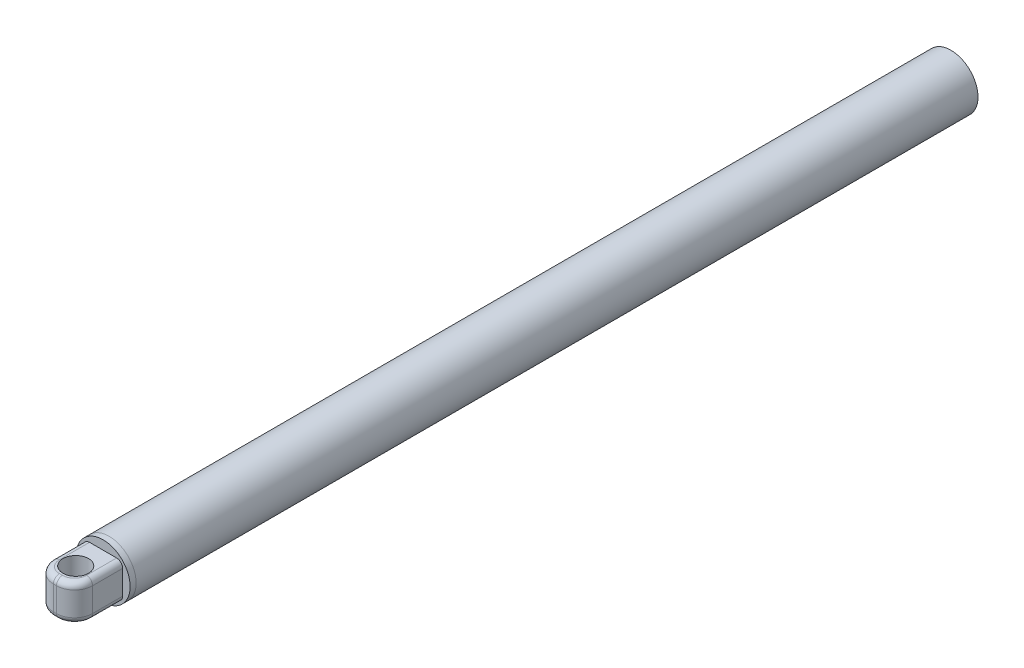
from build123d import *

# Parameters (mm, degrees)
SKETCH1_R                = 4.5
ROD_DEPTH                = 140
SKETCH2_R                = 4.5
BOSS_EXTRUDE2_DEPTH      = 1
BOSS_EXTRUDE4_DEPTH      = 3
BOSS_EXTRUDE4_DEPTH_BACK = 3
SKETCH4_R                = 2.125
FILLET2_R                = 1


with BuildPart() as part:
    # Sketch1 → Rod (new body)
    with BuildSketch(Plane.XY):
        Circle(SKETCH1_R)
    extrude(amount=ROD_DEPTH)


with BuildPart() as body_2:
    # Sketch2 → Boss-Extrude2 (new body)
    with BuildSketch(Plane.XY.offset(140)):
        Circle(SKETCH2_R)
    extrude(amount=BOSS_EXTRUDE2_DEPTH)

    # Sketch4 → Boss-Extrude4 (add, two sides: drawn at the far end of the back side and taken through both)
    with BuildSketch(Plane(origin=(0, 0, 0), x_dir=(1, 0, 0), z_dir=(0, 1, 0)).offset(-BOSS_EXTRUDE4_DEPTH_BACK)):
        with BuildLine():
            Line((-3.255351782, -141), (3.255351782, -141))
            Line((3.255351782, -141), (3.255351782, -146))
            ThreePointArc((3.255351782, -146), (2.376672125, -148.121320344), (0.255351782, -149))
            Line((0.255351782, -149), (-0.255351782, -149))
            ThreePointArc((-0.255351782, -149), (-2.376672125, -148.121320344), (-3.255351782, -146))
            Line((-3.255351782, -146), (-3.255351782, -141))
        make_face()
        with Locations((0, -145.54500745)):
            Circle(SKETCH4_R, mode=Mode.SUBTRACT)
    extrude(amount=BOSS_EXTRUDE4_DEPTH + BOSS_EXTRUDE4_DEPTH_BACK)

    # Fillet2
    fillet2_edges = [body_2.edges().sort_by_distance(p)[0] for p in [
        (-3.255351782, -3, 143.5),
        (-2.376672125, -3, 148.121320344),
        (0, -3, 149),
        (3.255351782, -3, 143.5),
        (-3.255351782, 3, 143.5),
        (-2.376672125, 3, 148.121320344),
        (0, 3, 149),
        (3.255351782, 3, 143.5),
        (2.376672125, -3, 148.121320344),
        (2.376672125, 3, 148.121320344),
    ]]
    fillet(fillet2_edges, radius=FILLET2_R)


solid = Compound([part.part, body_2.part])
